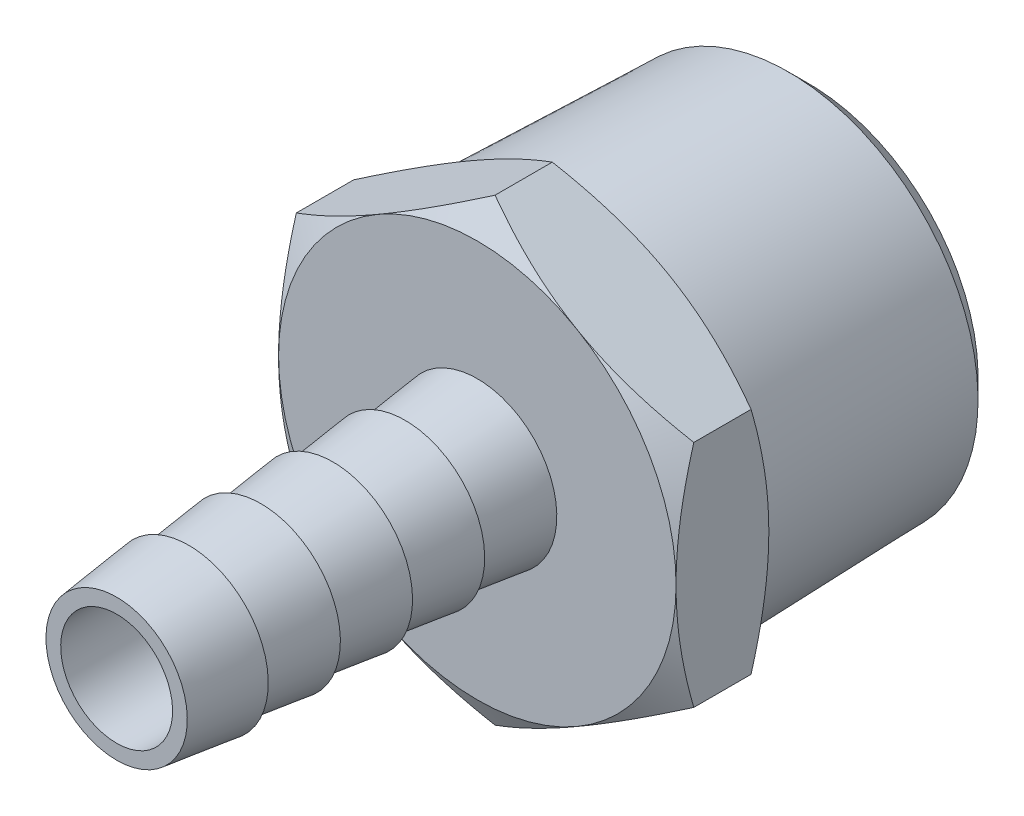
from build123d import *

# Parameters (mm, degrees)
LPATTERN1_COUNT     = 5
LPATTERN1_PITCH     = 4.9
BOSS_EXTRUDE1_START = -7.3
BOSS_EXTRUDE1_DEPTH = 6.3
SKETCH5_OUTSIDE_W   = 153.692
SKETCH5_OUTSIDE_H   = 157.868
SKETCH5_OUTSIDE_R   = 13.5
CUT_EXTRUDE1_DEPTH  = 33.023428923
CUT_EXTRUDE1_DRAFT  = -60
SKETCH6_OUTSIDE_W   = 171.16
SKETCH6_OUTSIDE_H   = 175.336
SKETCH6_OUTSIDE_R   = 13.5
CUT_EXTRUDE2_DEPTH  = 38.066022177
CUT_EXTRUDE2_DRAFT  = -60


with BuildPart() as part:
    # Sketch2 → Revolve2 (revolve)
    with BuildSketch(Plane(origin=(0, 0, 0), x_dir=(0, 0, -1), z_dir=(1, 0, 0)), mode=Mode.PRIVATE) as revolve2_sk:
        Polygon((-23.5, 4.8), (-18.6, 5.4), (-18.6, 0), (-23.5, 0), align=None)
    revolve(revolve2_sk.sketch.rotate(Axis((0, 0, 23.5), (0, 0, -1)), 180), axis=Axis((0, 0, 23.5), (0, 0, -1)))


with BuildPart() as lpattern1_1:
    # LPattern1: pattern copy
    add(part.part.moved(Location(Vector(0, 0, -1) * (1 * LPATTERN1_PITCH))))


with BuildPart() as lpattern1_2:
    # LPattern1: pattern copy
    add(part.part.moved(Location(Vector(0, 0, -1) * (2 * LPATTERN1_PITCH))))


with BuildPart() as lpattern1_3:
    # LPattern1: pattern copy
    add(part.part.moved(Location(Vector(0, 0, -1) * (3 * LPATTERN1_PITCH))))


with BuildPart() as lpattern1_4:
    # LPattern1: pattern copy
    add(part.part.moved(Location(Vector(0, 0, -1) * (4 * LPATTERN1_PITCH))))


with BuildPart() as body_6:
    # Sketch3 → Boss-Extrude1 (new body)
    with BuildSketch(Plane.XY.offset(BOSS_EXTRUDE1_START)):
        Polygon((0, 15.588457268), (-13.5, 7.794228634), (-13.5, -7.794228634), (0, -15.588457268), (13.5, -7.794228634), (13.5, 7.794228634), align=None)
    extrude(amount=BOSS_EXTRUDE1_DEPTH)


with BuildPart() as cut_extrude1_tool:
    # Sketch5 outside → Cut-Extrude1 (with draft: the straight prism first)
    with BuildSketch(Plane.XY.offset(-1)):
        Rectangle(SKETCH5_OUTSIDE_W, SKETCH5_OUTSIDE_H)
        Circle(SKETCH5_OUTSIDE_R, mode=Mode.SUBTRACT)
    extrude(amount=-CUT_EXTRUDE1_DEPTH)
    # Cut-Extrude1: the draft: its side faces are tilted about the plane it starts from
    cut_extrude1_sides = [cut_extrude1_tool.faces().sort_by_distance(p)[0] for p in [
        (0, -78.934, -17.511714462),
        (76.846, 0, -17.511714462),
        (0, 78.934, -17.511714462),
        (-76.846, 0, -17.511714462),
        (-13.5, 0, -17.511714462),
    ]]
    draft(cut_extrude1_sides, Plane.XY.offset(-1), CUT_EXTRUDE1_DRAFT)


with BuildPart() as body_6_1:
    add(body_6.part)

    # Cut-Extrude1: cut by cut_extrude1_tool
    add(cut_extrude1_tool.part, mode=Mode.SUBTRACT)


with BuildPart() as cut_extrude2_tool:
    # Sketch6 outside → Cut-Extrude2 (with draft: the straight prism first)
    with BuildSketch(Plane(origin=(0, 0, -7.3), x_dir=(-1, 0, 0), z_dir=(0, 0, -1))):
        Rectangle(SKETCH6_OUTSIDE_W, SKETCH6_OUTSIDE_H)
        Circle(SKETCH6_OUTSIDE_R, mode=Mode.SUBTRACT)
    extrude(amount=-CUT_EXTRUDE2_DEPTH)
    # Cut-Extrude2: the draft: its side faces are tilted about the plane it starts from
    cut_extrude2_sides = [cut_extrude2_tool.faces().sort_by_distance(p)[0] for p in [
        (0, -87.668, 11.733011088),
        (-85.58, 0, 11.733011088),
        (0, 87.668, 11.733011088),
        (85.58, 0, 11.733011088),
        (13.5, 0, 11.733011088),
    ]]
    draft(cut_extrude2_sides, Plane(origin=(0, 0, -7.3), x_dir=(-1, 0, 0), z_dir=(0, 0, -1)), CUT_EXTRUDE2_DRAFT)


with BuildPart() as body_6_2:
    add(body_6_1.part)

    # Cut-Extrude2: cut by cut_extrude2_tool
    add(cut_extrude2_tool.part, mode=Mode.SUBTRACT)


with BuildPart() as part_1:
    add(part.part)

    add(lpattern1_1.part)  # Revolve1 merges LPattern1_1

    add(lpattern1_2.part)  # Revolve1 merges LPattern1_2

    add(lpattern1_3.part)  # Revolve1 merges LPattern1_3

    add(lpattern1_4.part)  # Revolve1 merges LPattern1_4

    add(body_6_2.part)  # Revolve1 merges body 6
    # Sketch4 → Revolve1 (revolve)
    with BuildSketch(Plane(origin=(0, 0, 0), x_dir=(0, 0, -1), z_dir=(1, 0, 0)), mode=Mode.PRIVATE) as revolve1_sk:
        Polygon((-23.5, 4.8), (7.3, 4.8), (7.3, 13.335), (22.139285714, 12.872977456), (23.5, 11.51226317), (23.5, 0), (-23.5, 0), align=None)
    revolve(revolve1_sk.sketch.rotate(Axis((0, 0, 23.5), (0, 0, -1)), 180), axis=Axis((0, 0, 23.5), (0, 0, -1)))

    # Sketch7 → Cut-Revolve1 (revolve, cut)
    with BuildSketch(Plane(origin=(0, 0, 0), x_dir=(0, 0, -1), z_dir=(1, 0, 0)), mode=Mode.PRIVATE) as cut_revolve1_sk:
        Polygon((-23.5, 0), (-23.5, 3.8), (4.15, 3.8), (4.15, 9.3345), (23.5, 9.3345), (23.5, 0), align=None)
    revolve(cut_revolve1_sk.sketch.rotate(Axis((0, 0, 23.5), (0, 0, -1)), 180), axis=Axis((0, 0, 23.5), (0, 0, -1)), mode=Mode.SUBTRACT)


solid = part_1.part
